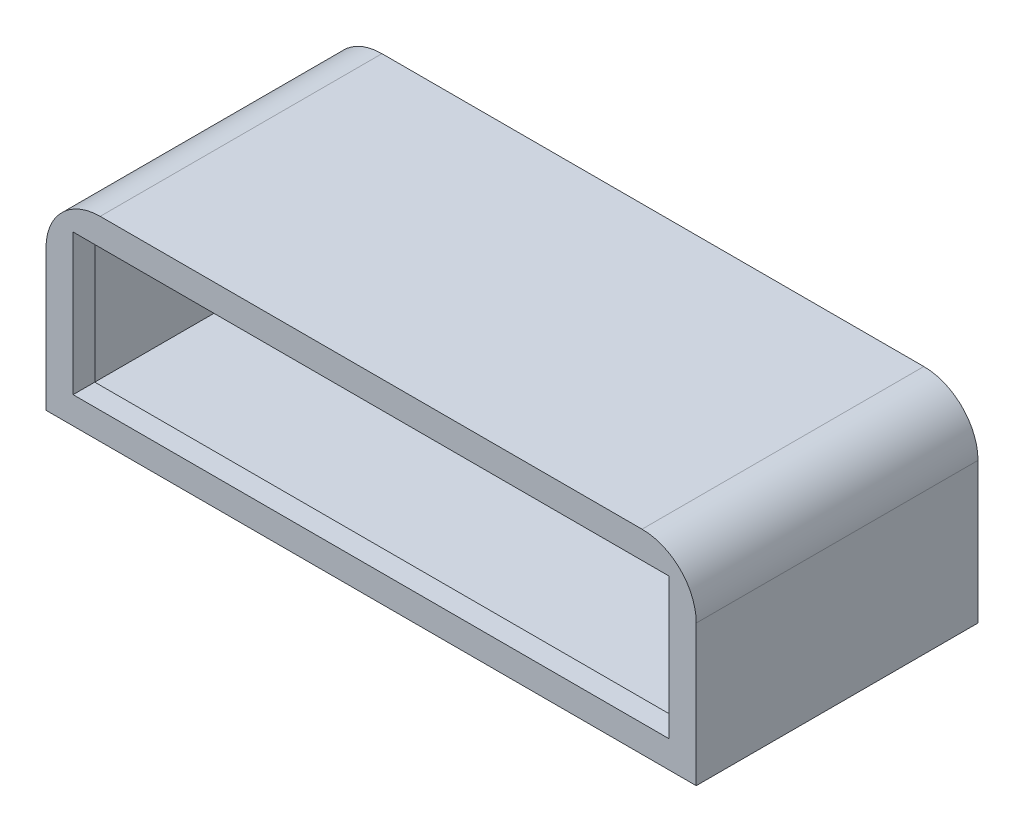
from build123d import *

# Parameters (mm, degrees)
SKETCH1_W           = 152.4
SKETCH1_H           = 45.72
BOSS_EXTRUDE2_DEPTH = 66.04
SHELL1_T            = -5.08
SKETCH2_W           = 139.7
SKETCH2_H           = 33.02
CUT_EXTRUDE1_DEPTH  = 13.462
FILLET1_R           = 12.7
SKETCH4_R           = 1
CUT_EXTRUDE2_DEPTH  = 3.175


with BuildPart() as part:
    # Sketch1 → Boss-Extrude2 (new body)
    with BuildSketch(Plane.XY):
        Rectangle(SKETCH1_W, SKETCH1_H)
    extrude(amount=BOSS_EXTRUDE2_DEPTH)

    # Shell1
    shell1_openings = [part.faces().sort_by_distance(p)[0] for p in [
        (0, 0, 0),
    ]]
    offset(amount=SHELL1_T, openings=shell1_openings, kind=Kind.INTERSECTION)

    # Sketch2 → Cut-Extrude1 (cut)
    with BuildSketch(Plane.XY.offset(66.04)):
        Rectangle(SKETCH2_W, SKETCH2_H)
    extrude(amount=-CUT_EXTRUDE1_DEPTH, mode=Mode.SUBTRACT)

    # Fillet1
    fillet1_edges = [part.edges().sort_by_distance(p)[0] for p in [
        (-76.2, 22.86, 33.02),
        (76.2, 22.86, 33.02),
    ]]
    fillet(fillet1_edges, radius=FILLET1_R)

    # Sketch4 → Cut-Extrude2 (cut)
    with BuildSketch(Plane(origin=(0, 0, 0), x_dir=(-1, 0, 0), z_dir=(0, 0, -1))):
        with Locations((-57.15, -20.32)):
            Circle(SKETCH4_R)
        with Locations((-57.15, 20.32)):
            Circle(SKETCH4_R)
        with Locations((57.15, 20.32)):
            Circle(SKETCH4_R)
        with Locations((57.15, -20.32)):
            Circle(SKETCH4_R)
    extrude(amount=-CUT_EXTRUDE2_DEPTH, mode=Mode.SUBTRACT)


solid = part.part
